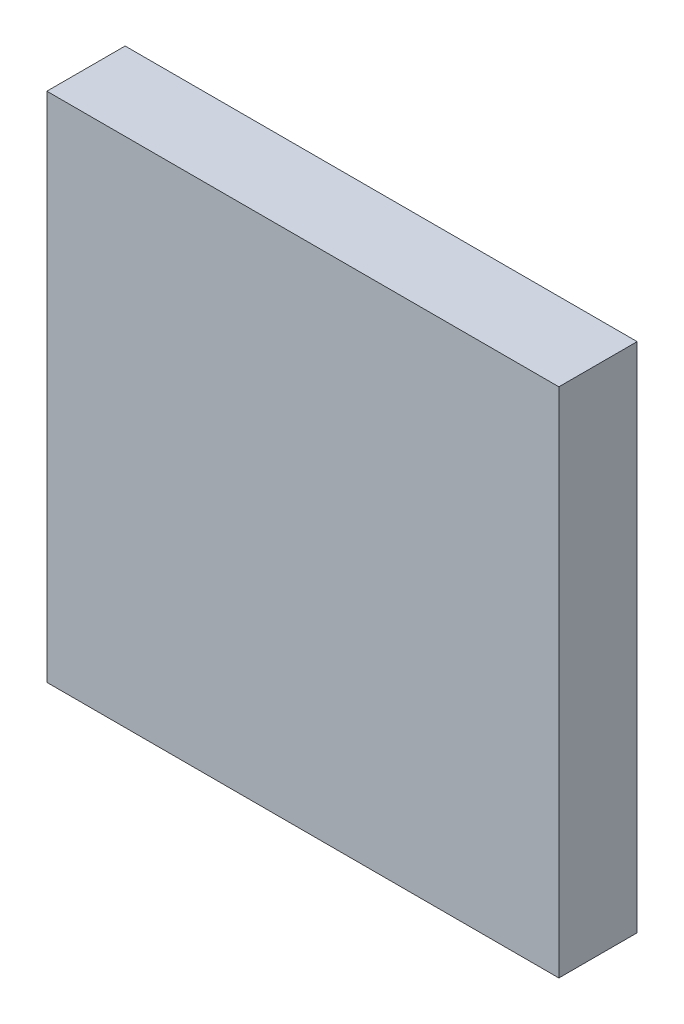
from build123d import *

# Parameters (mm, degrees)
SKETCH_1_W          = 70
SKETCH_1_H          = 70
EXTRUDE_1_DEPTH     = 10.7
SKETCH_2_W          = 60.5
SKETCH_2_H          = 60.5
CUT_EXTRUDE_1_DEPTH = 9.2


with BuildPart() as part:
    # Эскиз1 → Бобышка-Вытянуть1 (new body)
    with BuildSketch(Plane.XY):
        Rectangle(SKETCH_1_W, SKETCH_1_H)
    extrude(amount=-EXTRUDE_1_DEPTH)

    # Эскиз2 → Вырез-Вытянуть1 (cut)
    with BuildSketch(Plane(origin=(0, 0, -10.7), x_dir=(-1, 0, 0), z_dir=(0, 0, -1))):
        Rectangle(SKETCH_2_W, SKETCH_2_H)
    extrude(amount=-CUT_EXTRUDE_1_DEPTH, mode=Mode.SUBTRACT)


solid = part.part
